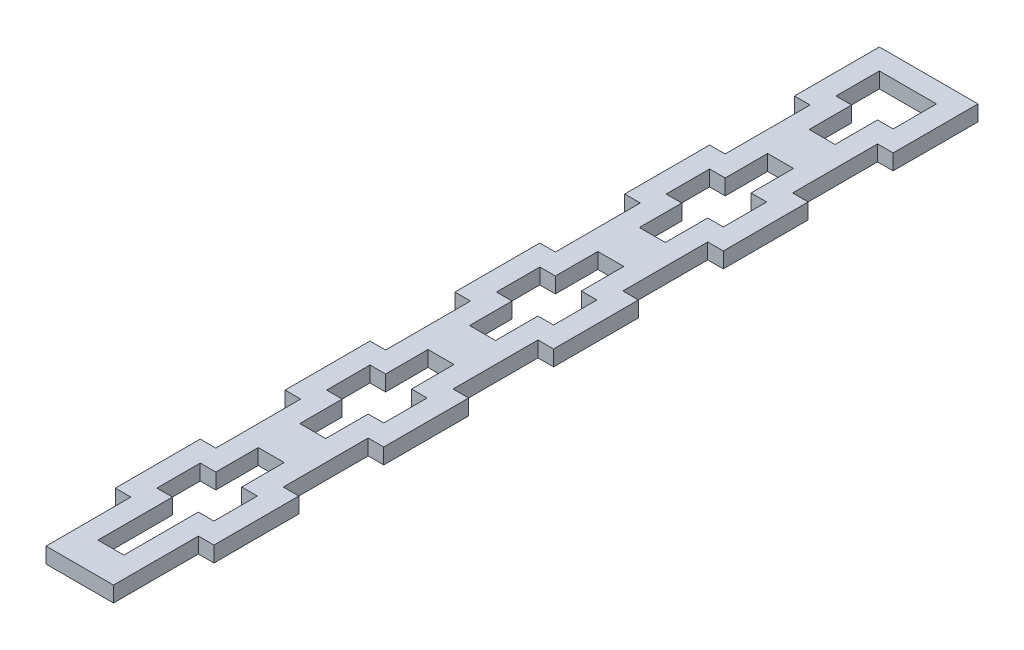
from build123d import *

# Parameters (mm, degrees)
BOSS_EXTRUDE1_DEPTH     = 3
SKETCH3_W               = 5
SKETCH3_H               = 6.177085
CUT_EXTRUDE1_DEPTH      = 1
CUT_EXTRUDE1_DEPTH_BACK = 4


with BuildPart() as part:
    # Sketch2 → Boss-Extrude1 (new body)
    with BuildSketch(Plane(origin=(0, 0, 0), x_dir=(1, 0, 0), z_dir=(0, 1, 0))):
        Polygon((-6.5, -81.77085), (-6.5, -98.12502), (6.5, -98.12502), (6.5, -81.77085), (9.5, -81.77085), (9.5, -65.41668), (6.5, -65.41668), (6.5, -49.06251), (9.5, -49.06251), (9.5, -32.70834), (6.5, -32.70834), (6.5, -16.35417), (9.5, -16.35417), (9.5, 0), (6.5, 0), (6.5, 16.35417), (9.5, 16.35417), (9.5, 32.70834), (6.5, 32.70834), (6.5, 49.06251), (9.5, 49.06251), (9.5, 65.41668), (6.5, 65.41668), (-6.5, 65.41668), (-9.5, 65.41668), (-9.5, 49.06251), (-6.5, 49.06251), (-6.5, 32.70834), (-9.5, 32.70834), (-9.5, 16.35417), (-6.5, 16.35417), (-6.5, 0), (-9.5, 0), (-9.5, -16.35417), (-6.5, -16.35417), (-6.5, -32.70834), (-9.5, -32.70834), (-9.5, -49.06251), (-6.5, -49.06251), (-6.5, -65.41668), (-9.5, -65.41668), (-9.5, -81.77085), align=None)
    extrude(amount=BOSS_EXTRUDE1_DEPTH)

    # Sketch3 → Cut-Extrude1 (cut, two sides)
    with BuildSketch(Plane(origin=(0, 3, 0), x_dir=(1, 0, 0), z_dir=(0, 1, 0))) as cut_extrude1_sk:
        Polygon((-5.5, 53.06251), (-5.5, 61.41668), (5.5, 61.41668), (5.5, 53.06251), (2.5, 53.06251), (2.5, 44.885425), (-2.5, 44.885425), (-2.5, 53.06251), align=None)
        Polygon((-2.5, 28.70834), (-2.5, 36.885425), (2.5, 36.885425), (2.5, 28.70834), (5.5, 28.70834), (5.5, 20.35417), (2.5, 20.35417), (2.5, 12.177085), (-2.5, 12.177085), (-2.5, 20.35417), (-5.5, 20.35417), (-5.5, 28.70834), align=None)
        Polygon((-5.5, -4), (-2.5, -4), (-2.5, 4.177085), (2.5, 4.177085), (2.5, -4), (5.5, -4), (5.5, -12.35417), (2.5, -12.35417), (2.5, -20.531255), (-2.5, -20.531255), (-2.5, -12.35417), (-5.5, -12.35417), align=None)
        Polygon((-5.5, -69.41668), (-2.5, -69.41668), (-2.5, -61.239595), (2.5, -61.239595), (2.5, -69.41668), (5.5, -69.41668), (5.5, -77.77085), (2.5, -77.77085), (2.5, -85.947935), (-2.5, -85.947935), (-2.5, -77.77085), (-5.5, -77.77085), align=None)
        with Locations((0, -89.0364775)):
            Rectangle(SKETCH3_W, SKETCH3_H)
        Polygon((-5.5, -36.70834), (-2.5, -36.70834), (-2.5, -28.531255), (2.5, -28.531255), (2.5, -36.70834), (5.5, -36.70834), (5.5, -45.06251), (2.5, -45.06251), (2.5, -53.239595), (-2.5, -53.239595), (-2.5, -45.06251), (-5.5, -45.06251), align=None)
    extrude(amount=CUT_EXTRUDE1_DEPTH, mode=Mode.SUBTRACT)
    extrude(cut_extrude1_sk.sketch, amount=-CUT_EXTRUDE1_DEPTH_BACK, mode=Mode.SUBTRACT)


solid = part.part
